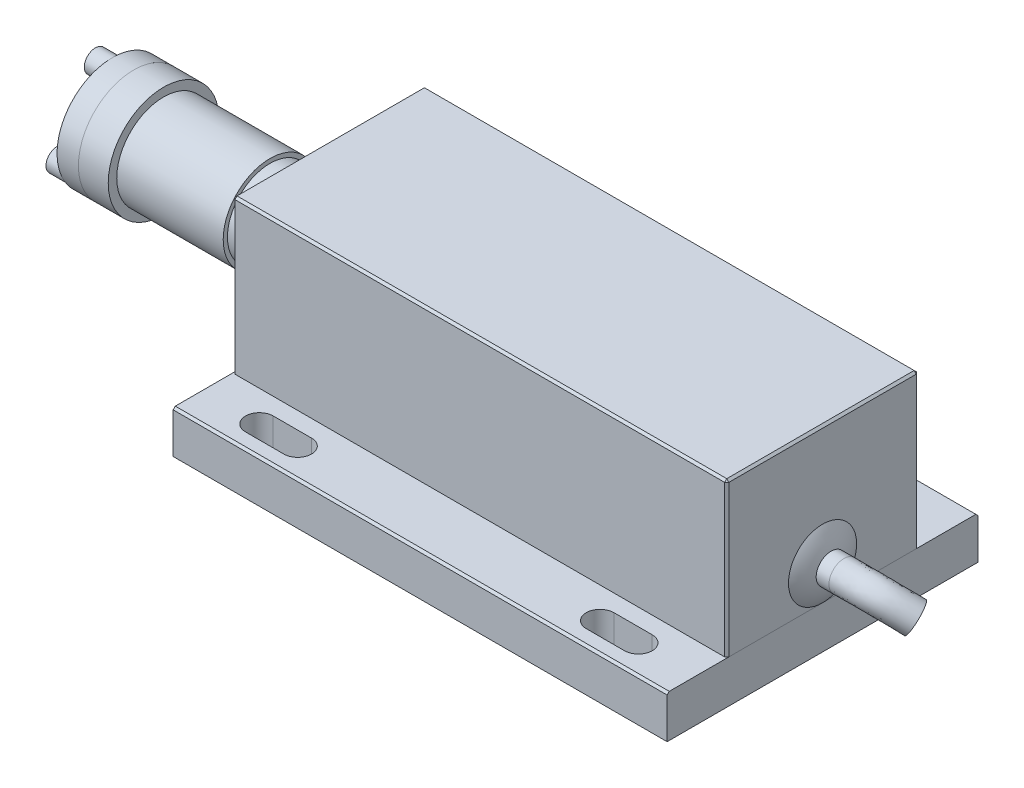
from build123d import *

# Parameters (mm, degrees)
SKETCH1_W           = 116
SKETCH1_H           = 73
BOSS_EXTRUDE1_DEPTH = 10
SKETCH2_W           = 116
SKETCH2_H           = 45
BOSS_EXTRUDE2_DEPTH = 36
SKETCH3_R           = 14.5
BOSS_EXTRUDE3_DEPTH = 1
SKETCH4_R           = 10
BOSS_EXTRUDE4_DEPTH = 12.75
SKETCH5_R           = 11
BOSS_EXTRUDE5_DEPTH = 25
SKETCH6_R           = 13
BOSS_EXTRUDE6_DEPTH = 7
SKETCH7_R           = 13
BOSS_EXTRUDE7_DEPTH = 5
SKETCH8_R           = 4
BOSS_EXTRUDE8_DEPTH = 5
CUT_EXTRUDE1_DEPTH  = 10
CHAMFER1_SIZE       = 0.5
CHAMFER2_SIZE       = 0.5
SKETCH10_R          = 3.5
SKETCH13_R          = 2.625
BOSS_EXTRUDE9_DEPTH = 4
CUT_EXTRUDE2_DEPTH  = 3


with BuildPart() as part:
    # Sketch1 → Boss-Extrude1 (new body)
    with BuildSketch(Plane(origin=(0, 0, 0), x_dir=(1, 0, 0), z_dir=(0, 1, 0))):
        with Locations((58, 0)):
            Rectangle(SKETCH1_W, SKETCH1_H)
    extrude(amount=BOSS_EXTRUDE1_DEPTH)

    # Sketch9 → Cut-Extrude1 (cut)
    with BuildSketch(Plane(origin=(0, 10, 0), x_dir=(1, 0, 0), z_dir=(0, 1, 0))):
        with BuildLine():
            Line((13.5, 33), (22.5, 33))
            ThreePointArc((22.5, 33), (25.75, 29.75), (22.5, 26.5))
            Line((22.5, 26.5), (13.5, 26.5))
            ThreePointArc((13.5, 26.5), (10.25, 29.75), (13.5, 33))
        make_face()
        with BuildLine():
            Line((93.5, 33), (102.5, 33))
            ThreePointArc((102.5, 33), (105.75, 29.75), (102.5, 26.5))
            Line((102.5, 26.5), (93.5, 26.5))
            ThreePointArc((93.5, 26.5), (90.25, 29.75), (93.5, 33))
        make_face()
        with BuildLine():
            Line((13.5, -33), (22.5, -33))
            ThreePointArc((22.5, -33), (25.75, -29.75), (22.5, -26.5))
            Line((22.5, -26.5), (13.5, -26.5))
            ThreePointArc((13.5, -26.5), (10.25, -29.75), (13.5, -33))
        make_face()
        with BuildLine():
            Line((93.5, -33), (102.5, -33))
            ThreePointArc((102.5, -33), (105.75, -29.75), (102.5, -26.5))
            Line((102.5, -26.5), (93.5, -26.5))
            ThreePointArc((93.5, -26.5), (90.25, -29.75), (93.5, -33))
        make_face()
    extrude(amount=-CUT_EXTRUDE1_DEPTH, mode=Mode.SUBTRACT)

    # Chamfer1
    chamfer1_edges = [part.edges().sort_by_distance(p)[0] for p in [
        (58, 10, -36.5),
        (58, 10, 36.5),
    ]]
    chamfer(chamfer1_edges, length=CHAMFER1_SIZE)


with BuildPart() as body_2:
    # Sketch2 → Boss-Extrude2 (new body)
    with BuildSketch(Plane(origin=(0, 10, 0), x_dir=(1, 0, 0), z_dir=(0, 1, 0))):
        with Locations((58, 0)):
            Rectangle(SKETCH2_W, SKETCH2_H)
    extrude(amount=BOSS_EXTRUDE2_DEPTH)

    # Chamfer2
    chamfer2_edges = [body_2.edges().sort_by_distance(p)[0] for p in [
        (116, 46, 0),
        (58, 46, -22.5),
        (0, 46, 0),
        (58, 46, 22.5),
        (0, 28, -22.5),
        (116, 28, -22.5),
        (116, 28, 22.5),
        (0, 28, 22.5),
    ]]
    chamfer(chamfer2_edges, length=CHAMFER2_SIZE)

    # Sweep1: sweep along a curve in space
    with BuildLine() as sweep1_path:
        Line((116, 18, 0), (121, 18, 0))
        add(Edge.make_bspline(
            [(121, 18, 0), (128.398710809, 18, 0), (128.249160874, 18.894172802, 0.865355974), (134.449130149, 14.508245339, -3.37922463)],
            knots=[0, 0, 0, 0, 1, 1, 1, 1], degree=3))
    # Sketch10 → Sweep1 (sweep)
    with BuildSketch(Plane(origin=(116, 0, 0), x_dir=(0, 0, -1), z_dir=(1, 0, 0))):
        with Locations((0, 18)):
            Circle(SKETCH10_R)
    sweep(path=sweep1_path.line)

    # Sketch11 → Revolve1 (revolve)
    with BuildSketch(Plane(origin=(0, 0, 0), x_dir=(-1, 0, 0), z_dir=(0, 0, -1))):
        with BuildLine():
            Line((-116, 18), (-116, 26))
            ThreePointArc((-116, 26), (-117.8111125, 22.18085644), (-118.432743778, 18))
            Line((-118.432743778, 18), (-116, 18))
        make_face()
    revolve(axis=Axis((116, 18, 0), (1, 0, 0)))


with BuildPart() as body_3:
    # Sketch3 → Boss-Extrude3 (new body)
    with BuildSketch(Plane.ZY):
        with Locations((0, 24.5)):
            Circle(SKETCH3_R)
    extrude(amount=BOSS_EXTRUDE3_DEPTH)


with BuildPart() as body_4:
    # Sketch4 → Boss-Extrude4 (new body)
    with BuildSketch(Plane.ZY.offset(1)):
        with Locations((0, 24.5)):
            Circle(SKETCH4_R)
    extrude(amount=BOSS_EXTRUDE4_DEPTH)


with BuildPart() as body_5:
    # Sketch5 → Boss-Extrude5 (new body)
    with BuildSketch(Plane.ZY.offset(13.75)):
        with Locations((0, 24.5)):
            Circle(SKETCH5_R)
    extrude(amount=BOSS_EXTRUDE5_DEPTH)


with BuildPart() as body_6:
    # Sketch6 → Boss-Extrude6 (new body)
    with BuildSketch(Plane.ZY.offset(38.75)):
        with Locations((0, 24.5)):
            Circle(SKETCH6_R)
    extrude(amount=BOSS_EXTRUDE6_DEPTH)


with BuildPart() as body_7:
    # Sketch7 → Boss-Extrude7 (new body)
    with BuildSketch(Plane.ZY.offset(45.75)):
        with Locations((0, 24.5)):
            Circle(SKETCH7_R)
    extrude(amount=BOSS_EXTRUDE7_DEPTH)

    # Sketch13 → Boss-Extrude9 (add)
    with BuildSketch(Plane.ZY.offset(50.75)):
        with Locations((0, 34.875)):
            Circle(SKETCH13_R)
        with Locations((8.985013564, 19.3125)):
            Circle(SKETCH13_R)
        with Locations((-8.985013564, 19.3125)):
            Circle(SKETCH13_R)
    extrude(amount=BOSS_EXTRUDE9_DEPTH)

    # Sketch14 → Cut-Extrude2 (cut)
    with BuildSketch(Plane.ZY.offset(54.75)):
        Polygon((-1.75, 35.885362971), (0, 36.895725942), (1.75, 35.885362971), (1.75, 33.864637029), (0, 32.854274058), (-1.75, 33.864637029), align=None)
        Polygon((-7.235013564, 18.302137029), (-8.985013564, 17.291774058), (-10.735013564, 18.302137029), (-10.735013564, 20.322862971), (-8.985013564, 21.333225942), (-7.235013564, 20.322862971), align=None)
        Polygon((8.985013564, 21.333225942), (10.735013564, 20.322862971), (10.735013564, 18.302137029), (8.985013564, 17.291774058), (7.235013564, 18.302137029), (7.235013564, 20.322862971), align=None)
    extrude(amount=-CUT_EXTRUDE2_DEPTH, mode=Mode.SUBTRACT)


with BuildPart() as body_8:
    # Sketch8 → Boss-Extrude8 (new body)
    with BuildSketch(Plane.ZY.offset(50.75)):
        with Locations((0, 24.5)):
            Circle(SKETCH8_R)
    extrude(amount=BOSS_EXTRUDE8_DEPTH)


solid = Compound([part.part, body_2.part, body_3.part, body_4.part, body_5.part, body_6.part, body_7.part, body_8.part])
